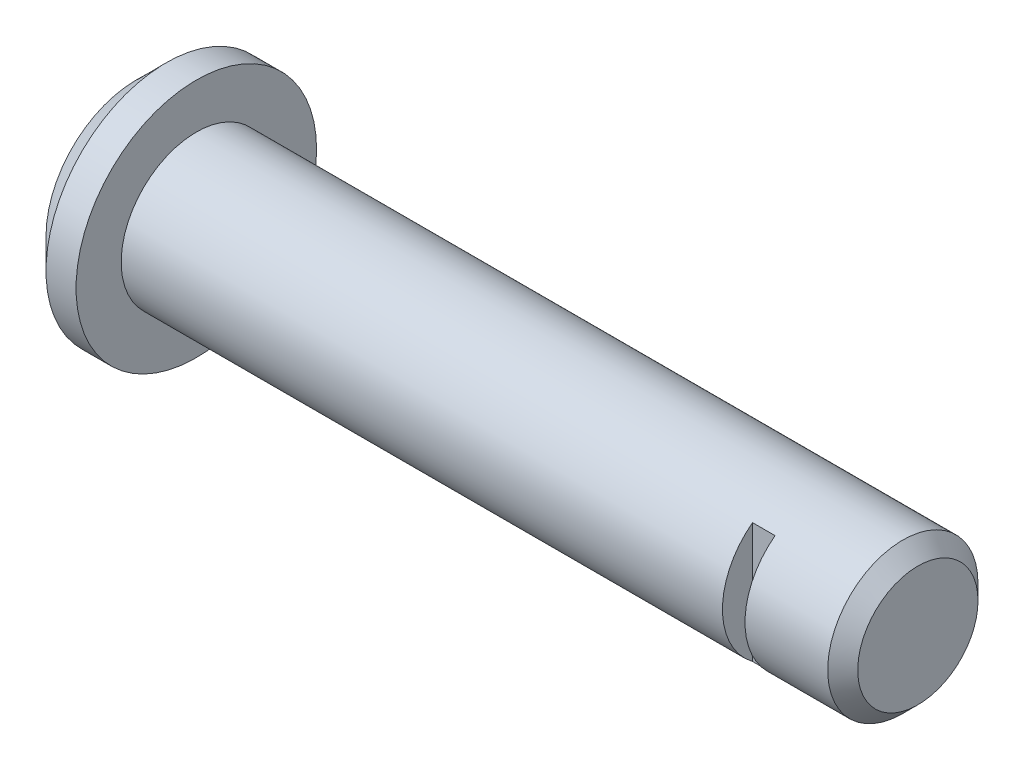
from build123d import *

# Parameters (mm, degrees)
CUT_EXTRUDE2_DEPTH      = 1
CUT_EXTRUDE2_DEPTH_BACK = 57


with BuildPart() as part:
    # Sketch1 → Revolve1 (revolve)
    with BuildSketch(Plane(origin=(0, 0, 0), x_dir=(1, 0, 0), z_dir=(0, 1, 0))):
        Polygon((0, 0), (94, 0), (96, 2), (96, 10), (-8, 10), (-8, -2), (-4, -6), (0, -6), align=None)
    revolve(axis=Axis((67.877257865, 0, -10), (-1, 0, 0)))

    # Sketch2 → Cut-Extrude2 (cut, two sides)
    with BuildSketch(Plane(origin=(0, 40, 0), x_dir=(1, 0, 0), z_dir=(0, 1, 0))) as cut_extrude2_sk:
        Polygon((80, -199.282857121), (80, 0), (80, 4), (83, 4), (83, 0), (83, -199.282857121), (83, -597.848571364), (80, -597.848571364), align=None)
    extrude(amount=CUT_EXTRUDE2_DEPTH, mode=Mode.SUBTRACT)
    extrude(cut_extrude2_sk.sketch, amount=-CUT_EXTRUDE2_DEPTH_BACK, mode=Mode.SUBTRACT)


solid = part.part
